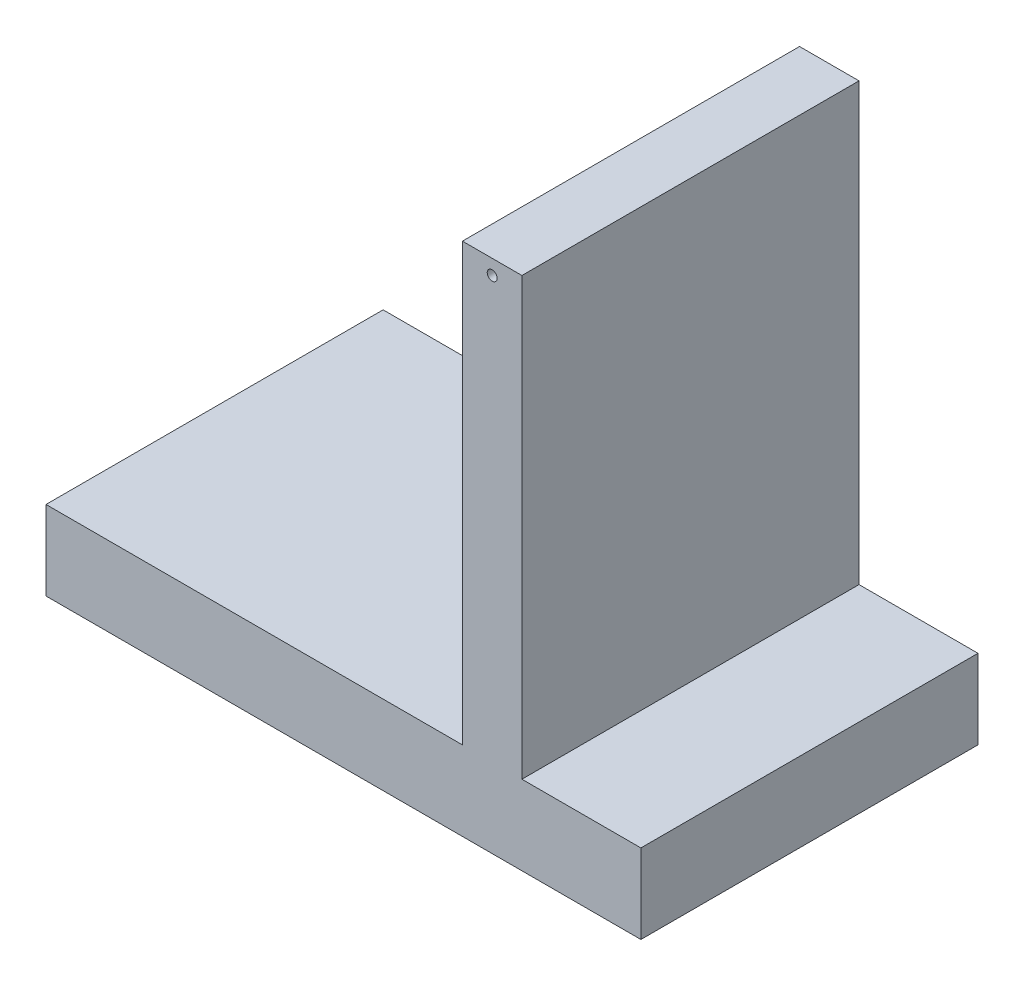
from build123d import *

# Parameters (mm, degrees)
SKETCH1_W           = 762
SKETCH1_H           = 101.6
SKETCH1_W_2         = 76.2
SKETCH1_H_2         = 558.8
BOSS_EXTRUDE1_DEPTH = 215.9
SKETCH2_R           = 6.35
CUT_EXTRUDE1_DEPTH  = 432.8


with BuildPart() as part:
    # Sketch1 → Boss-Extrude1 (new body, symmetric)
    with BuildSketch(Plane.XY):
        Rectangle(SKETCH1_W, SKETCH1_H)
        with Locations((190.5, 330.2)):
            Rectangle(SKETCH1_W_2, SKETCH1_H_2)
    extrude(amount=BOSS_EXTRUDE1_DEPTH, both=True)

    # Sketch2 → Cut-Extrude1 (cut, through all)
    with BuildSketch(Plane.XY.offset(215.9)):
        with Locations((190.5, 590.55)):
            Circle(SKETCH2_R)
    extrude(amount=-CUT_EXTRUDE1_DEPTH, mode=Mode.SUBTRACT)


solid = part.part
